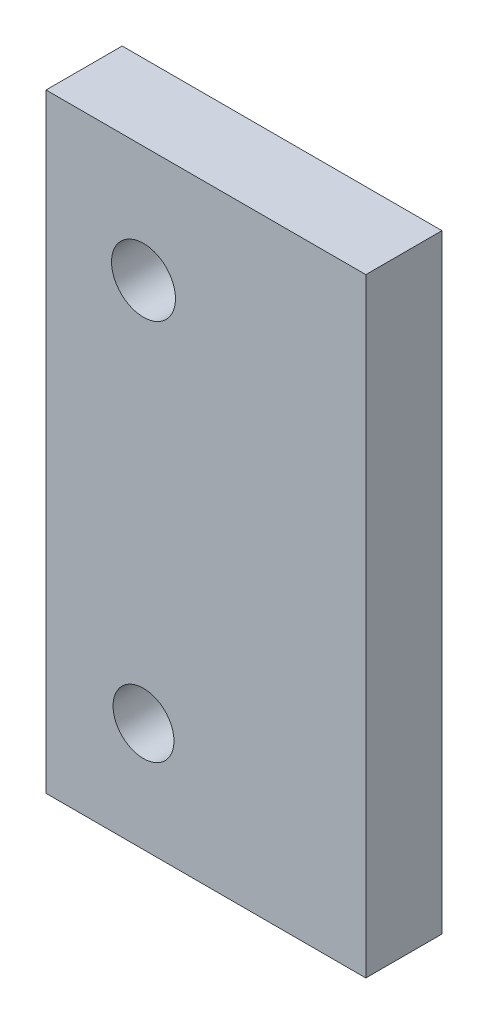
from build123d import *

# Parameters (mm, degrees)
SKETCH2_W           = 10.5
SKETCH2_H           = 20
BOSS_EXTRUDE1_DEPTH = 2.5
SKETCH3_R           = 1.05
SKETCH3_R_2         = 1
CUT_EXTRUDE1_DEPTH  = 3.5


with BuildPart() as part:
    # Sketch2 → Boss-Extrude1 (new body)
    with BuildSketch(Plane.XY):
        with Locations((5.25, 10)):
            Rectangle(SKETCH2_W, SKETCH2_H)
    extrude(amount=BOSS_EXTRUDE1_DEPTH)

    # Sketch3 → Cut-Extrude1 (cut, through all)
    with BuildSketch(Plane.XY.offset(2.5)):
        with Locations((3.2, 16.188280357)):
            Circle(SKETCH3_R)
        with Locations((3.2, 3.588280357)):
            Circle(SKETCH3_R_2)
    extrude(amount=-CUT_EXTRUDE1_DEPTH, mode=Mode.SUBTRACT)


solid = part.part
